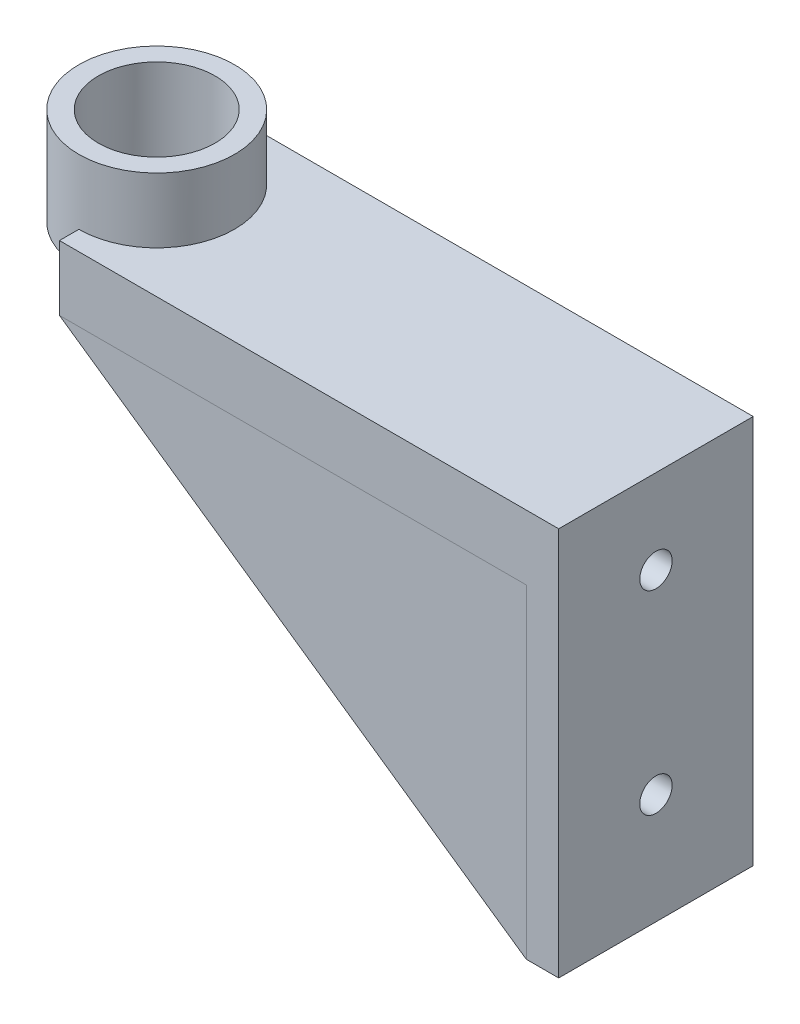
from build123d import *

# Parameters (mm, degrees)
SKETCH1_R           = 12
SKETCH1_R_2         = 9
BOSS_EXTRUDE1_DEPTH = 15
SKETCH2_W           = 30
SKETCH2_H           = 10
BOSS_EXTRUDE2_DEPTH = 77
CUT_EXTRUDE3_DEPTH  = 5
SKETCH5_W           = 5
SKETCH5_H           = 30
BOSS_EXTRUDE3_DEPTH = 50
SKETCH6_R           = 2.5
CUT_EXTRUDE4_DEPTH  = 5
BOSS_EXTRUDE4_DEPTH = 5
BOSS_EXTRUDE5_DEPTH = 5


with BuildPart() as part:
    # Sketch1 → Boss-Extrude1 (new body)
    with BuildSketch(Plane(origin=(0, 0, 0), x_dir=(1, 0, 0), z_dir=(0, 1, 0))):
        Circle(SKETCH1_R)
        Circle(SKETCH1_R_2, mode=Mode.SUBTRACT)
    extrude(amount=BOSS_EXTRUDE1_DEPTH)

    # Sketch2 → Boss-Extrude2 (add)
    with BuildSketch(Plane(origin=(0, 0, 0), x_dir=(0, 0, -1), z_dir=(1, 0, 0))):
        Rectangle(SKETCH2_W, SKETCH2_H)
    extrude(amount=BOSS_EXTRUDE2_DEPTH)

    # Sketch4 → Cut-Extrude3 (cut)
    with BuildSketch(Plane(origin=(0, 5, 0), x_dir=(1, 0, 0), z_dir=(0, 1, 0))):
        with BuildLine():
            Line((0, 9), (0, -9))
            ThreePointArc((0, -9), (9, 0), (0, 9))
        make_face()
    extrude(amount=-CUT_EXTRUDE3_DEPTH, mode=Mode.SUBTRACT)

    # Sketch5 → Boss-Extrude3 (add)
    with BuildSketch(Plane.XZ.offset(5)):
        with Locations((74.5, 0)):
            Rectangle(SKETCH5_W, SKETCH5_H)
    extrude(amount=BOSS_EXTRUDE3_DEPTH)

    # Sketch6 → Cut-Extrude4 (cut)
    with BuildSketch(Plane.ZY.offset(-72)):
        with Locations((0, -8)):
            Circle(SKETCH6_R)
        with Locations((0, -38)):
            Circle(SKETCH6_R)
    extrude(amount=-CUT_EXTRUDE4_DEPTH, mode=Mode.SUBTRACT)

    # Sketch7 → Boss-Extrude4 (add)
    with BuildSketch(Plane(origin=(0, 0, -15), x_dir=(-1, 0, 0), z_dir=(0, 0, -1))):
        Polygon((-72, -55), (0, -5), (-72, -5), align=None)
    extrude(amount=-BOSS_EXTRUDE4_DEPTH)


with BuildPart() as body_2:
    # Sketch8 → Boss-Extrude5 (new body)
    with BuildSketch(Plane.XY.offset(15)):
        Polygon((0, -5), (72, -5), (72, -55), align=None)
    extrude(amount=-BOSS_EXTRUDE5_DEPTH)


solid = Compound([part.part, body_2.part])
